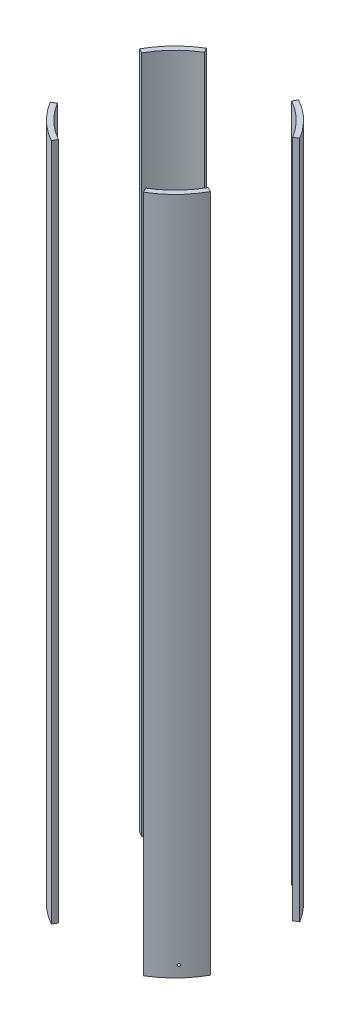
from build123d import *

# Parameters (mm, degrees)
SKETCH2_R               = 88.9
SKETCH2_R_2             = 83.82
BOSS_EXTRUDE1_DEPTH     = 331.730223
CUT_EXTRUDE1_DEPTH      = 332.730223
CUT_EXTRUDE1_DEPTH_BACK = 332.730223
SKETCH5_R               = 1.27
BOLT_HOLES_DEPTH        = 29.911624556
BOLT_PATTERN_COUNT      = 4


with BuildPart() as part:
    # Sketch2 → Boss-Extrude1 (new body, symmetric)
    with BuildSketch(Plane(origin=(0, 0, 0), x_dir=(1, 0, 0), z_dir=(0, 1, 0))):
        Circle(SKETCH2_R)
        Circle(SKETCH2_R_2, mode=Mode.SUBTRACT)
    extrude(amount=BOSS_EXTRUDE1_DEPTH, both=True)

    # Sketch3 → Cut-Extrude1 (cut, two sides)
    with BuildSketch(Plane(origin=(0, 0, 0), x_dir=(1, 0, 0), z_dir=(0, 1, 0))) as cut_extrude1_sk:
        Polygon((169.661755759, -94.300371224), (0, 0), (169.661755759, 101.677593364), align=None)
        Polygon((0, 0), (53.900027233, 96.974944394), (-58.116685864, 96.974944394), align=None)
        Polygon((-123.741299607, 68.777140945), (-123.741299607, -74.157652604), (0, 0), align=None)
        Polygon((-65.840936026, -118.45858783), (0, 0), (70.991745134, -118.45858783), align=None)
    extrude(amount=CUT_EXTRUDE1_DEPTH, mode=Mode.SUBTRACT)
    extrude(cut_extrude1_sk.sketch, amount=-CUT_EXTRUDE1_DEPTH_BACK, mode=Mode.SUBTRACT)

    # Sketch5 → Bolt holes (cut, through all)
    with BuildSketch(Plane(origin=(-56.309218645, 0, 58.175814955), x_dir=(-0.718540152, 0, -0.695485478), z_dir=(0.695485478, 0, -0.718540152))):
        with Locations((-1.29201311, -320.617723)):
            Circle(SKETCH5_R)
    bolt_holes = extrude(amount=-BOLT_HOLES_DEPTH, mode=Mode.SUBTRACT)

    # Bolt pattern: Bolt holes ×4 about axis
    bolt_pattern_axis = Axis((0, 331.730223, 0), (0, 1, 0))
    for i in range(1, BOLT_PATTERN_COUNT):
        add(bolt_holes.rotate(bolt_pattern_axis, i * 360 / BOLT_PATTERN_COUNT), mode=Mode.SUBTRACT)


solid = part.part
